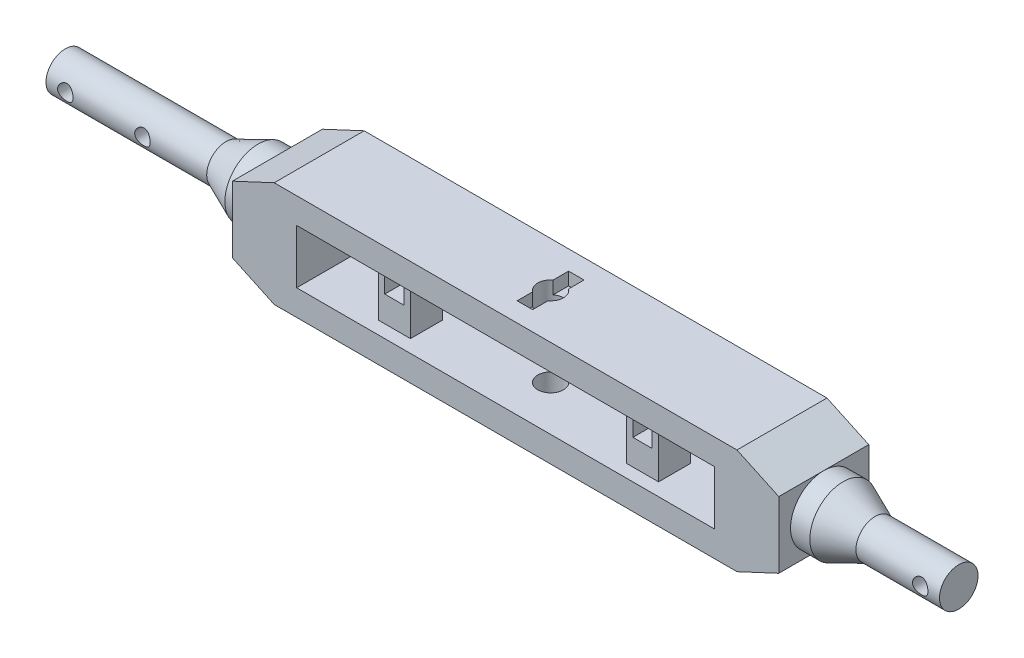
from build123d import *

# Parameters (mm, degrees)
SKETCH1_W                   = 32.5
SKETCH1_H                   = 4.2
BASEFORM_DEPTH              = 7
SKETCH2_R                   = 1
HUMERUSAXLEHOLE1_DEPTH      = 2
HUMERUSAXLELOCK_DEPTH       = 1
SKETCH6_R                   = 1.5
AXLEEXTENSION_DEPTH         = 6
SKETCH7_R                   = 0.6
SCREWHOLES_DEPTH            = 54.273445543
SCREWHOLES_DEPTH_BACK       = 54.273445543
SKETCH8_W                   = 2.5
SKETCH8_H                   = 2.5
HUMERUSTUBEHOLDERBASE_DEPTH = 4.2
SKETCH13_W                  = 1.5
SKETCH13_H                  = 1.5
TUBECLIPENTRANCE_DEPTH      = 2
SKETCH14_W                  = 1.5
SKETCH14_H                  = 1.5
CABLECLIPLOCKSLOT_DEPTH     = 0.7
SKETCH15_W                  = 1.5
SKETCH15_H                  = 0.2
TUBECLIPLOCKCLEARANCE_DEPTH = 2
SKETCH12_R                  = 1
HUMERUSAXLEHOLE2_DEPTH      = 54.818584249


with BuildPart() as part:
    # Sketch1 → BaseForm (new body)
    with BuildSketch(Plane.XY):
        Polygon((0, -2.584500111), (0, 2.584500111), (3.25, 4.1), (39.25, 4.1), (42.5, 2.584500111), (42.5, -2.584500111), (39.25, -4.1), (3.25, -4.1), align=None)
        with Locations((21.25, 0)):
            Rectangle(SKETCH1_W, SKETCH1_H, mode=Mode.SUBTRACT)
    extrude(amount=BASEFORM_DEPTH)

    # Sketch2 → HumerusAxleHole1 (cut)
    with BuildSketch(Plane(origin=(0, 4.1, 0), x_dir=(1, 0, 0), z_dir=(0, 1, 0))):
        with Locations(Location((21.25, -3.5, 0), (0, 0, 270))):
            Circle(SKETCH2_R)
    extrude(amount=-HUMERUSAXLEHOLE1_DEPTH, mode=Mode.SUBTRACT)

    # Sketch2_4 → HumerusAxleLock (cut)
    with BuildSketch(Plane(origin=(0, 4.1, 0), x_dir=(1, 0, 0), z_dir=(0, 1, 0))):
        with BuildLine():
            ThreePointArc((20.65, -2.7), (21.25, -2.5), (21.85, -2.7))
            Line((21.85, -2.7), (21.85, -1.5))
            Line((21.85, -1.5), (20.65, -1.5))
            Line((20.65, -1.5), (20.65, -2.7))
        make_face()
        with BuildLine():
            Line((21.85, -5.5), (21.85, -4.3))
            ThreePointArc((21.85, -4.3), (21.25, -4.5), (20.65, -4.3))
            Line((20.65, -4.3), (20.65, -5.5))
            Line((20.65, -5.5), (21.85, -5.5))
        make_face()
    extrude(amount=-HUMERUSAXLELOCK_DEPTH, mode=Mode.SUBTRACT)

    # Sketch5 → Axle (revolve)
    with BuildSketch(Plane.XY.offset(3.5), mode=Mode.PRIVATE) as axle_sk:
        Polygon((53, 0), (53, 1.5), (46.5, 1.5), (44, 2.584500111), (42.5, 2.584500111), (42.5, 0), align=None)
    axle = revolve(axle_sk.sketch.rotate(Axis((42.5, 0, 3.5), (1, 0, 0)), 90), axis=Axis((42.5, 0, 3.5), (1, 0, 0)))

    # Axle2: Axle across plane
    add(axle.mirror(Plane.ZY.offset(-21.25)))

    # Sketch6 → AxleExtension (add)
    with BuildSketch(Plane.ZY.offset(10.5)):
        with Locations((3.5, 0)):
            Circle(SKETCH6_R)
    extrude(amount=AXLEEXTENSION_DEPTH)

    # Sketch7 → ScrewHoles (cut, two sides)
    with BuildSketch(Plane.XY.offset(3.5)) as screwholes_sk:
        with Locations((-9, 0)):
            Circle(SKETCH7_R)
        with Locations((-15, 0)):
            Circle(SKETCH7_R)
        with Locations((51.5, 0)):
            Circle(SKETCH7_R)
    extrude(amount=SCREWHOLES_DEPTH, mode=Mode.SUBTRACT)
    extrude(screwholes_sk.sketch, amount=-SCREWHOLES_DEPTH_BACK, mode=Mode.SUBTRACT)

    # Sketch8 → HumerusTubeHolderBase (add)
    with BuildSketch(Plane(origin=(0, 2.1, 0), x_dir=(1, 0, 0), z_dir=(0, 1, 0))):
        with Locations((11.6, -4.75)):
            Rectangle(SKETCH8_W, SKETCH8_H)
    humerustubeholderbase = extrude(amount=-HUMERUSTUBEHOLDERBASE_DEPTH)

    # Sketch13 → TubeClipEntrance (cut)
    with BuildSketch(Plane.XY.offset(6)):
        with Locations((11.6, 0.65)):
            Rectangle(SKETCH13_W, SKETCH13_H)
    tubeclipentrance = extrude(amount=-TUBECLIPENTRANCE_DEPTH, mode=Mode.SUBTRACT)

    # Sketch14 → CableClipLockSlot (cut)
    with BuildSketch(Plane.XZ.offset(-1.4)):
        with Locations((11.6, 4.75)):
            Rectangle(SKETCH14_W, SKETCH14_H)
    cablecliplockslot = extrude(amount=-CABLECLIPLOCKSLOT_DEPTH, mode=Mode.SUBTRACT)

    # Sketch15 → TubeClipLockClearance (cut)
    with BuildSketch(Plane.XY.offset(6)):
        with Locations((11.6, 1.5)):
            Rectangle(SKETCH15_W, SKETCH15_H)
    tubecliplockclearance = extrude(amount=-TUBECLIPLOCKCLEARANCE_DEPTH, mode=Mode.SUBTRACT)

    # Sketch12 → HumerusAxleHole2 (cut, through all)
    with BuildSketch(Plane(origin=(0, -2.1, 0), x_dir=(1, 0, 0), z_dir=(0, 1, 0))):
        with Locations(Location((21.25, -3.5, 0), (0, 0, 306.869897646))):
            Circle(SKETCH12_R)
    extrude(amount=-HUMERUSAXLEHOLE2_DEPTH, mode=Mode.SUBTRACT)

    # TubeClipSlot2: HumerusTubeHolderBase, TubeClipEntrance, CableClipLockSlot, TubeClipLockClearance across plane
    add(humerustubeholderbase.mirror(Plane(origin=(21.25, 0, 0), x_dir=(0, 0, 1), z_dir=(1, 0, 0))))
    add(tubeclipentrance.mirror(Plane(origin=(21.25, 0, 0), x_dir=(0, 0, 1), z_dir=(1, 0, 0))), mode=Mode.SUBTRACT)
    add(cablecliplockslot.mirror(Plane(origin=(21.25, 0, 0), x_dir=(0, 0, 1), z_dir=(1, 0, 0))), mode=Mode.SUBTRACT)
    add(tubecliplockclearance.mirror(Plane(origin=(21.25, 0, 0), x_dir=(0, 0, 1), z_dir=(1, 0, 0))), mode=Mode.SUBTRACT)


solid = part.part
